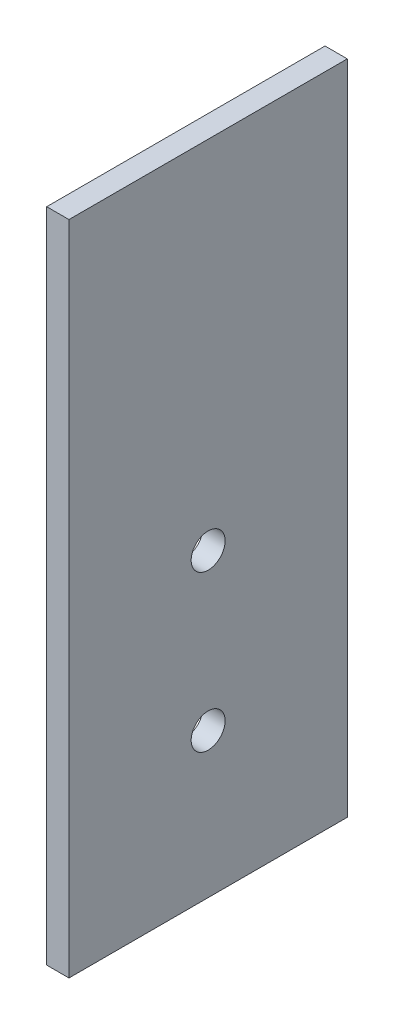
from build123d import *

# Parameters (mm, degrees)
SKETCH1_W           = 25
SKETCH1_H           = 59
BOSS_EXTRUDE1_DEPTH = 2
SKETCH3_R           = 1.525
CUT_EXTRUDE1_DEPTH  = 3


with BuildPart() as part:
    # Sketch1 → Boss-Extrude1 (new body)
    with BuildSketch(Plane(origin=(0, 0, 0), x_dir=(0, 0, -1), z_dir=(1, 0, 0))):
        with Locations((-12.5, 12.604395604)):
            Rectangle(SKETCH1_W, SKETCH1_H)
    extrude(amount=BOSS_EXTRUDE1_DEPTH)

    # Sketch3 → Cut-Extrude1 (cut, through all)
    with BuildSketch(Plane.ZY):
        with Locations((12.5, -3.895604396)):
            Circle(SKETCH3_R)
        with Locations((12.5, 10.104395604)):
            Circle(SKETCH3_R)
    extrude(amount=-CUT_EXTRUDE1_DEPTH, mode=Mode.SUBTRACT)


solid = part.part
